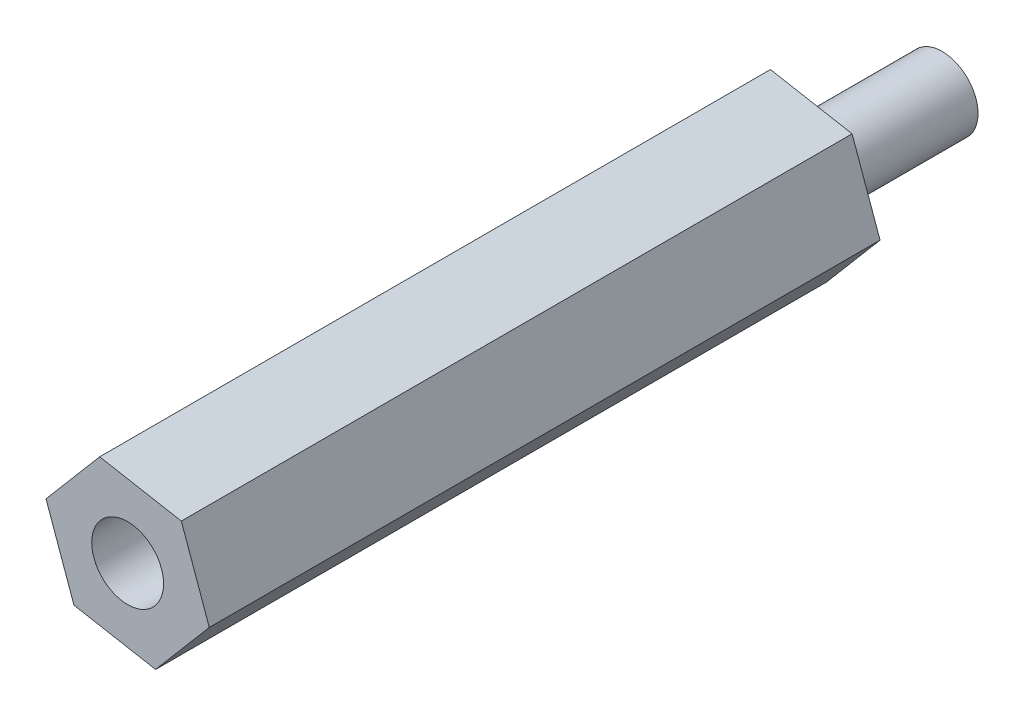
from build123d import *

# Parameters (mm, degrees)
RESSALTO_EXTRUS_O1_DEPTH = 28
ESBO_O4_R                = 1.5
CORTE_EXTRUS_O2_DEPTH    = 40
ESBO_O6_R                = 1.5
RESSALTO_EXTRUS_O2_DEPTH = 6


with BuildPart() as part:
    # Esboço1 → Ressalto-extrusão1 (new body)
    with BuildSketch(Plane.XY):
        Polygon((12.933175524, -4.143885809), (9.525050306, -3.523658029), (7.283854683, -6.165067156), (8.450784277, -9.426704064), (11.858909495, -10.046931845), (14.100105118, -7.405522718), align=None)
    extrude(amount=RESSALTO_EXTRUS_O1_DEPTH)

    # Esboço4 → Corte-extrusão2 (cut)
    with BuildSketch(Plane(origin=(0, 0, 0), x_dir=(-1, 0, 0), z_dir=(0, 0, -1))):
        with Locations((-10.691979901, -6.785294937)):
            Circle(ESBO_O4_R)
    extrude(amount=-CORTE_EXTRUS_O2_DEPTH, mode=Mode.SUBTRACT)


with BuildPart() as body_2:
    # Esboço6 → Ressalto-extrusão2 (new body)
    with BuildSketch(Plane(origin=(0, 0, 0), x_dir=(-1, 0, 0), z_dir=(0, 0, -1))):
        with Locations((-10.691979901, -6.785294937)):
            Circle(ESBO_O6_R)
    extrude(amount=RESSALTO_EXTRUS_O2_DEPTH)


solid = Compound([part.part, body_2.part])
